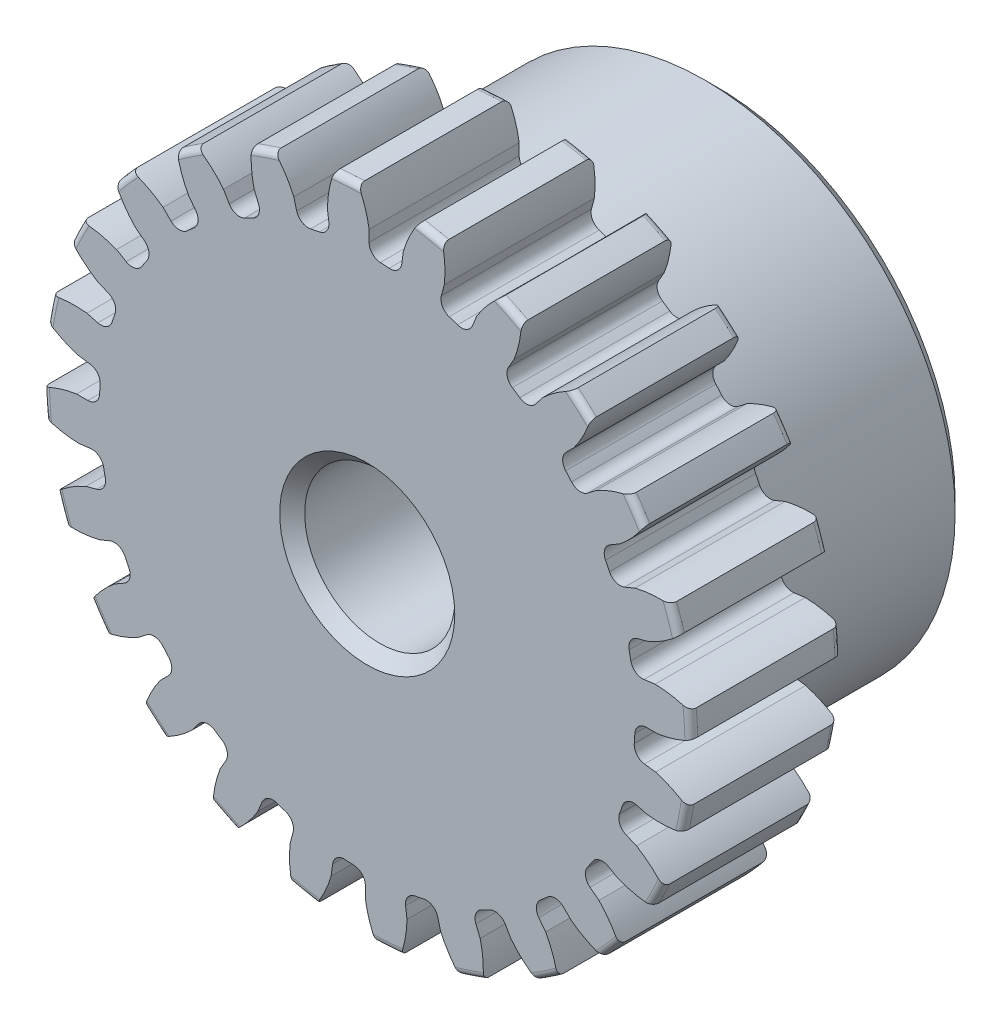
from build123d import *

# Parameters (mm, degrees)
SKETCH1_R                = 10.287
BOSS_EXTRUDE1_DEPTH      = 4.7625
SKETCH2_W                = 6.35
SKETCH2_H                = 7.9375
REVOLVE1_ANGLE           = 360
FILLET2_R                = 0.20574
CUT_EXTRUDE1_DEPTH       = 12.1125
FILLET1_R                = 0.37404675
CIRPATTERN1_COUNT        = 24
FILLET1_OF_CIRPATTERN1_R = 0.37404675
SKETCH5_R                = 2.38125
CUT_EXTRUDE2_DEPTH       = 12.1125
CHAMFER1_SIZE            = 0.396875


with BuildPart() as part:
    # Sketch1 → Boss-Extrude1 (new body)
    with BuildSketch(Plane.XY):
        Circle(SKETCH1_R)
    extrude(amount=-BOSS_EXTRUDE1_DEPTH)

    # Sketch2 → Revolve1 (revolve, symmetric)
    with BuildSketch(Plane(origin=(0, 0, 0), x_dir=(0, 0, -1), z_dir=(1, 0, 0))) as revolve1_sk:
        with Locations((7.9375, 3.96875)):
            Rectangle(SKETCH2_W, SKETCH2_H)
    revolve(axis=Axis((0, 0, -4.7625), (0, 0, -1)), revolution_arc=REVOLVE1_ANGLE / 2)
    revolve(revolve1_sk.sketch, axis=Axis((0, 0, -4.7625), (0, 0, 1)), revolution_arc=REVOLVE1_ANGLE / 2)

    # Fillet2
    fillet2_edges = [part.edges().sort_by_distance(p)[0] for p in [
        (-10.287, 0, 0),
        (-10.287, 0, -4.7625),
        (0, -7.9375, -4.7625),
    ]]
    fillet(fillet2_edges, radius=FILLET2_R)

    # Sketch4 → Cut-Extrude1 (cut, through all)
    with BuildSketch(Plane.XY):
        with BuildLine():
            Line((0.059789782, 9.221412444), (0.059789782, 8.50085224))
            ThreePointArc((0.059789782, 8.50085224), (0.555997388, 8.482860988), (1.050308183, 8.435930082))
            Line((1.050308183, 8.435930082), (1.144360382, 9.150325765))
            add(Edge.make_bspline(
                [(2.406507179, 10.971914406), (1.453557654, 10.222687936), (1.144360382, 9.150325765)],
                knots=[0, 0, 0, 1, 1, 1], degree=2))
            ThreePointArc((2.406507179, 10.971914406), (0.734657289, 11.208677942), (-0.953793542, 11.192160668))
            add(Edge.make_bspline(
                [(-0.953793542, 11.192160668), (-0.106790576, 10.324958803), (0.059789782, 9.221412444)],
                knots=[0, 0, 0, 1, 1, 1], degree=2))
        make_face()
    cut_extrude1 = extrude(amount=-CUT_EXTRUDE1_DEPTH, mode=Mode.SUBTRACT)

    # Fillet1
    fillet1_edges = [part.edges().sort_by_distance(p)[0] for p in [
        (1.050308183, 8.435930082, -2.38125),
        (0.059789782, 8.50085224, -2.38125),
    ]]
    fillet(fillet1_edges, radius=FILLET1_R)

    # CirPattern1: Cut-Extrude1 ×24 about axis
    cirpattern1_axis = Axis((0, 0, -4.7625), (0, 0, 1))
    for i in range(1, CIRPATTERN1_COUNT):
        add(cut_extrude1.rotate(cirpattern1_axis, i * 360 / CIRPATTERN1_COUNT), mode=Mode.SUBTRACT)

    # Fillet1 of CirPattern1
    fillet1_of_cirpattern1_edges = [part.edges().sort_by_distance(p)[0] for p in [
        (-1.168859568, 8.420322496, -2.38125),
        (-2.142429965, 8.226667459, -2.38125),
        (-3.308371472, 7.830883847, -2.38125),
        (-4.19864665, 7.391848885, -2.38125),
        (-5.222423328, 6.707783405, -2.38125),
        (-5.968732505, 6.053288025, -2.38125),
        (-6.780575664, 5.12755861, -2.38125),
        (-7.332059103, 4.30220559, -2.38125),
        (-7.876642974, 3.197899168, -2.38125),
        (-8.19571799, 2.257934954, -2.38125),
        (-8.435930082, 1.050308183, -2.38125),
        (-8.50085224, 0.059789782, -2.38125),
        (-8.420322496, -1.168859568, -2.38125),
        (-8.226667459, -2.142429965, -2.38125),
        (-7.830883847, -3.308371472, -2.38125),
        (-7.391848885, -4.19864665, -2.38125),
        (-6.707783405, -5.222423328, -2.38125),
        (-6.053288025, -5.968732505, -2.38125),
        (-5.12755861, -6.780575664, -2.38125),
        (-4.30220559, -7.332059103, -2.38125),
        (-3.197899168, -7.876642974, -2.38125),
        (-2.257934954, -8.19571799, -2.38125),
        (-1.050308183, -8.435930082, -2.38125),
        (-0.059789782, -8.50085224, -2.38125),
        (1.168859568, -8.420322496, -2.38125),
        (2.142429965, -8.226667459, -2.38125),
        (3.308371472, -7.830883847, -2.38125),
        (4.19864665, -7.391848885, -2.38125),
        (5.222423328, -6.707783405, -2.38125),
        (5.968732505, -6.053288025, -2.38125),
        (6.780575664, -5.12755861, -2.38125),
        (7.332059103, -4.30220559, -2.38125),
        (7.876642974, -3.197899168, -2.38125),
        (8.19571799, -2.257934954, -2.38125),
        (8.435930082, -1.050308183, -2.38125),
        (8.50085224, -0.059789782, -2.38125),
        (8.420322496, 1.168859568, -2.38125),
        (8.226667459, 2.142429965, -2.38125),
        (7.830883847, 3.308371472, -2.38125),
        (7.391848885, 4.19864665, -2.38125),
        (6.707783405, 5.222423328, -2.38125),
        (6.053288025, 5.968732505, -2.38125),
        (5.12755861, 6.780575664, -2.38125),
        (4.30220559, 7.332059103, -2.38125),
        (3.197899168, 7.876642974, -2.38125),
        (2.257934954, 8.19571799, -2.38125),
    ]]
    fillet(fillet1_of_cirpattern1_edges, radius=FILLET1_OF_CIRPATTERN1_R)

    # Sketch5 → Cut-Extrude2 (cut, through all)
    with BuildSketch(Plane.XY):
        Circle(SKETCH5_R)
    extrude(amount=-CUT_EXTRUDE2_DEPTH, mode=Mode.SUBTRACT)

    # Chamfer1
    chamfer1_edges = [part.edges().sort_by_distance(p)[0] for p in [
        (-2.38125, 0, -11.1125),
        (-2.38125, 0, 0),
        (0, -7.9375, -11.1125),
    ]]
    chamfer(chamfer1_edges, length=CHAMFER1_SIZE)


solid = part.part
